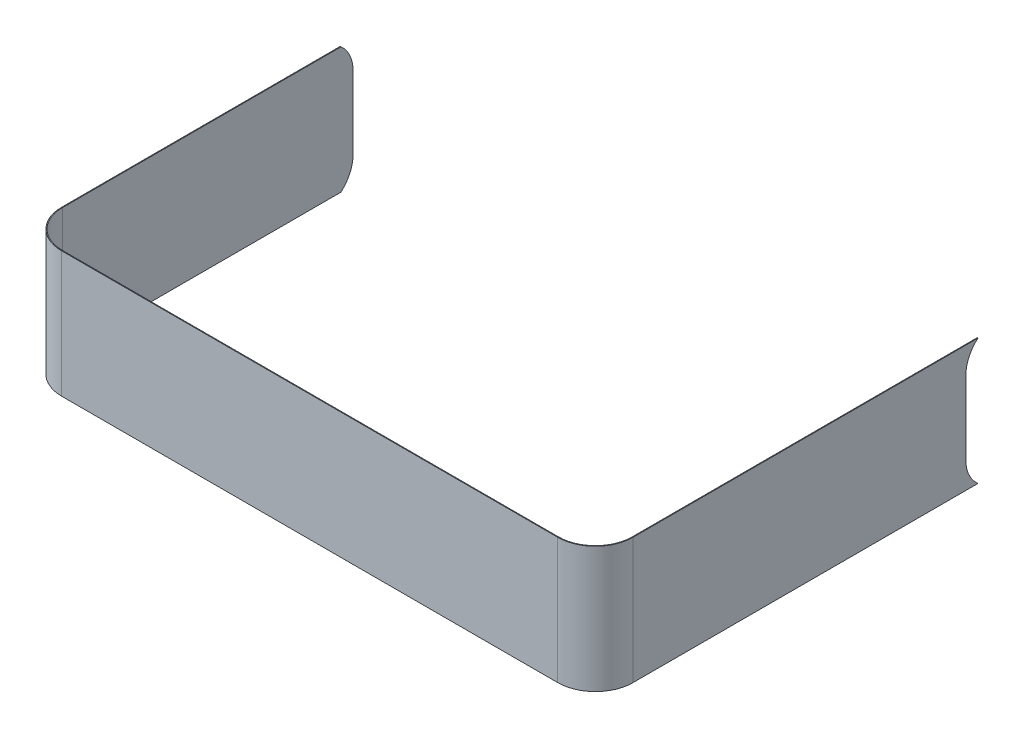
from build123d import *

# Parameters (mm, degrees)
BOSS_EXTRUDE2_DEPTH = 1672
CUT_EXTRUDE2_DEPTH  = 20
CUT_EXTRUDE3_DEPTH  = 20


with BuildPart() as part:
    # Sketch2 → Boss-Extrude2 (new body)
    with BuildSketch(Plane(origin=(0, 0, 0), x_dir=(1, 0, 0), z_dir=(0, 1, 0))):
        with BuildLine():
            Line((0, 0), (6590, 0))
            ThreePointArc((6590, 0), (6943.553390593, 146.446609407), (7090, 500))
            Line((7090, 500), (7090, 8890))
            Line((7090, 8890), (7080, 8890))
            Line((7080, 8890), (7080, 500))
            ThreePointArc((7080, 500), (6936.482322781, 153.517677219), (6590, 10))
            Line((6590, 10), (0, 10))
            ThreePointArc((0, 10), (-346.482322781, 153.517677219), (-490, 500))
            Line((-490, 500), (-490, 8890))
            Line((-490, 8890), (-500, 8890))
            Line((-500, 8890), (-500, 500))
            ThreePointArc((-500, 500), (-353.553390593, 146.446609407), (0, 0))
        make_face()
    extrude(amount=-BOSS_EXTRUDE2_DEPTH)

    # Sketch3 → Cut-Extrude2 (cut)
    with BuildSketch(Plane.ZY.offset(500)):
        with BuildLine():
            Line((-4822, 110), (-3902, 110))
            ThreePointArc((-3902, 110), (-4227.269119346, -24.730880654), (-4362, -350))
            Line((-4362, -350), (-4362, -1322))
            ThreePointArc((-4362, -1322), (-4260.95507876, -1609.665172436), (-4002.211950294, -1770.951628818))
            Line((-4002.211950294, -1770.951628818), (-4822, -1782))
            Line((-4822, -1782), (-9056.882603438, -1782))
            Line((-9056.882603438, -1782), (-9056.882603438, 110))
            Line((-9056.882603438, 110), (-4822, 110))
        make_face()
    extrude(amount=-CUT_EXTRUDE2_DEPTH, mode=Mode.SUBTRACT)

    # Sketch4 → Cut-Extrude3 (cut)
    with BuildSketch(Plane(origin=(7090, 0, 0), x_dir=(0, 0, -1), z_dir=(1, 0, 0))):
        with BuildLine():
            Line((5380, 110), (9554.66965043, 110))
            Line((9554.66965043, 110), (9554.66965043, -1782))
            Line((9554.66965043, -1782), (5380, -1782))
            ThreePointArc((5380, -1782), (5054.730880654, -1647.269119346), (4920, -1322))
            Line((4920, -1322), (4920, -350))
            ThreePointArc((4920, -350), (5054.730880654, -24.730880654), (5380, 110))
        make_face()
    extrude(amount=-CUT_EXTRUDE3_DEPTH, mode=Mode.SUBTRACT)


solid = part.part
